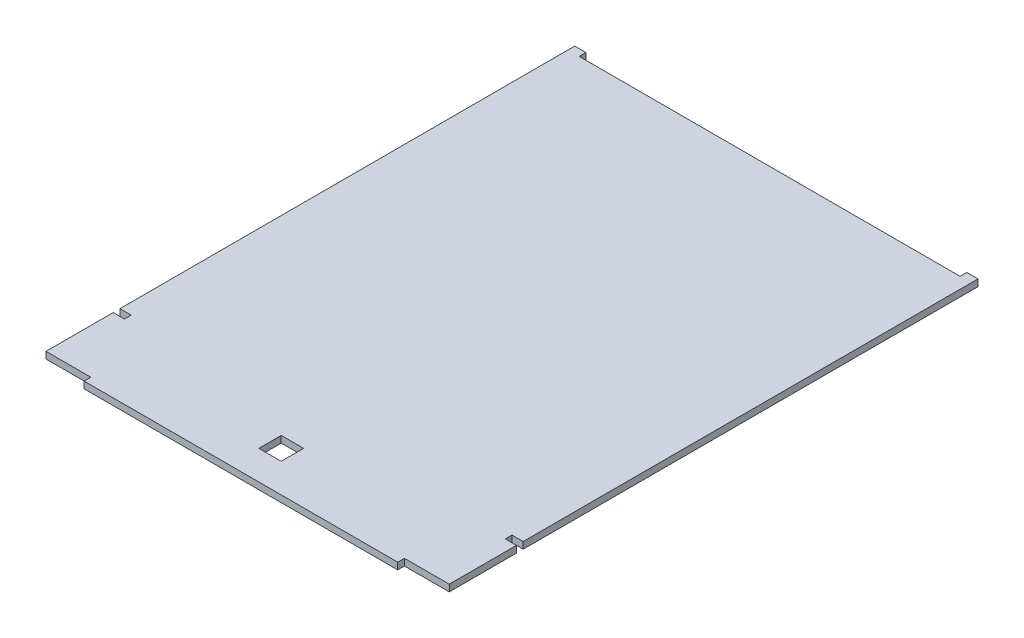
from build123d import *

# Parameters (mm, degrees)
SKETCH_1_W      = 10
SKETCH_1_H      = 10
EXTRUDE_1_DEPTH = 3


with BuildPart() as part:
    # 草图1 → 凸台-拉伸1 (new body)
    with BuildSketch(Plane(origin=(0, 0, 0), x_dir=(1, 0, 0), z_dir=(0, 1, 0))):
        Polygon((160, -3), (180, -3), (180, 0), (180, 27), (175, 27), (175, 30), (180, 30), (180, 230), (180, 233), (175, 233), (175, 230), (5, 230), (5, 233), (0, 233), (0, 230), (0, 30), (5, 30), (5, 27), (0, 27), (0, 0), (0, -3), (20, -3), (20, -6), (160, -6), align=None)
        with Locations((90, 12)):
            Rectangle(SKETCH_1_W, SKETCH_1_H, mode=Mode.SUBTRACT)
    extrude(amount=EXTRUDE_1_DEPTH)


solid = part.part
